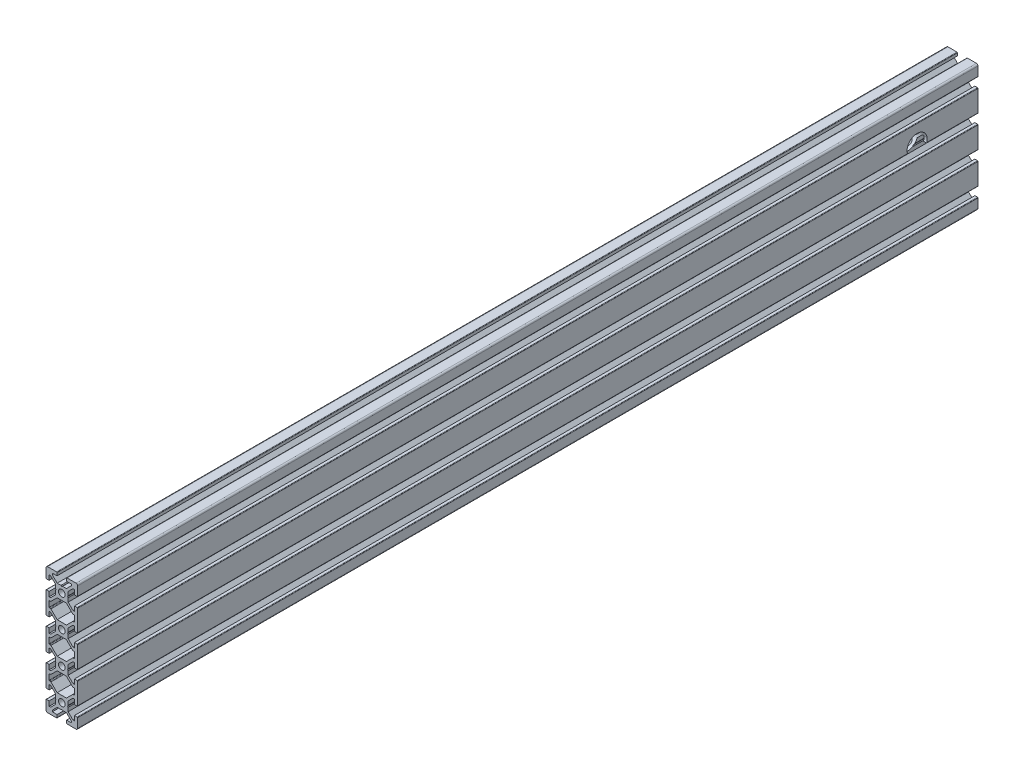
from build123d import *

# Parameters (mm, degrees)
SKETCH1_R           = 2.1
BOSS_EXTRUDE1_DEPTH = 569.5
SKETCH2_R           = 6.35
CUT_EXTRUDE1_DEPTH  = 20


with BuildPart() as part:
    # Sketch1 → Boss-Extrude1 (new body)
    with BuildSketch(Plane.XY):
        with BuildLine():
            Line((-9.7, -7), (-8, -7))
            Line((-8, -7), (-8, -4))
            Line((-8, -4), (-7.060612, -4))
            Line((-7.060612, -4), (-4, -7.06061195))
            Line((-4, -7.06061195), (-4, -9.480384758))
            Line((-4, -9.480384758), (-3.7, -10))
            Line((-3.7, -10), (-4, -10.519615242))
            Line((-4, -10.519615242), (-4, -12.939317))
            Line((-4, -12.939317), (-7.0606825, -16))
            Line((-7.0606825, -16), (-8, -16))
            Line((-8, -16), (-8, -13))
            Line((-8, -13), (-9.699997, -13))
            ThreePointArc((-9.699997, -13), (-9.912129034, -13.087871001), (-10, -13.30000305))
            Line((-10, -13.30000305), (-10, -26.699997))
            ThreePointArc((-10, -26.699997), (-9.912129041, -26.912129041), (-9.699997, -27))
            Line((-9.699997, -27), (-8, -27))
            Line((-8, -27), (-8, -24))
            Line((-8, -24), (-7.0606325, -24))
            Line((-7.0606325, -24), (-4, -27.0606334))
            Line((-4, -27.0606334), (-4, -29.480384758))
            Line((-4, -29.480384758), (-3.7, -30))
            Line((-3.7, -30), (-4, -30.519615242))
            Line((-4, -30.519615242), (-4, -32.9393376))
            Line((-4, -32.9393376), (-7.060661, -36))
            Line((-7.060661, -36), (-8, -36))
            Line((-8, -36), (-8, -33))
            Line((-8, -33), (-9.699997, -33))
            ThreePointArc((-9.699997, -33), (-9.912129041, -33.087870959), (-10, -33.300003))
            Line((-10, -33.300003), (-10, -39))
            ThreePointArc((-10, -39), (-9.707106781, -39.707106781), (-9, -40))
            Line((-9, -40), (-3.30000305, -40))
            ThreePointArc((-3.30000305, -40), (-3.087869903, -39.912135436), (-3, -39.7000045))
            Line((-3, -39.7000045), (-3, -38))
            Line((-3, -38), (-6, -38))
            Line((-6, -38), (-6, -37.060659))
            Line((-6, -37.060659), (-2.9393408, -34))
            Line((-2.9393408, -34), (-0.519615242, -34))
            Line((-0.519615242, -34), (0, -33.7))
            Line((0, -33.7), (0.519615242, -34))
            Line((0.519615242, -34), (2.9393408, -34))
            Line((2.9393408, -34), (6, -37.060659))
            Line((6, -37.060659), (6, -38))
            Line((6, -38), (3, -38))
            Line((3, -38), (3, -39.7000045))
            ThreePointArc((3, -39.7000045), (3.087869903, -39.912135436), (3.30000305, -40))
            Line((3.30000305, -40), (9, -40))
            ThreePointArc((9, -40), (9.707106781, -39.707106781), (10, -39))
            Line((10, -39), (10, -33.300003))
            ThreePointArc((10, -33.300003), (9.912129041, -33.087870959), (9.699997, -33))
            Line((9.699997, -33), (8, -33))
            Line((8, -33), (8, -36))
            Line((8, -36), (7.060661, -36))
            Line((7.060661, -36), (4, -32.9393376))
            Line((4, -32.9393376), (4, -30.519615242))
            Line((4, -30.519615242), (3.7, -30))
            Line((3.7, -30), (4, -29.480384758))
            Line((4, -29.480384758), (4, -27.0606334))
            Line((4, -27.0606334), (7.0606325, -24))
            Line((7.0606325, -24), (8, -24))
            Line((8, -24), (8, -27))
            Line((8, -27), (9.699997, -27))
            ThreePointArc((9.699997, -27), (9.912129041, -26.912129041), (10, -26.699997))
            Line((10, -26.699997), (10, -13.30000305))
            ThreePointArc((10, -13.30000305), (9.912129034, -13.087871001), (9.699997, -13))
            Line((9.699997, -13), (8, -13))
            Line((8, -13), (8, -16))
            Line((8, -16), (7.0606825, -16))
            Line((7.0606825, -16), (4, -12.939317))
            Line((4, -12.939317), (4, -10.519615242))
            Line((4, -10.519615242), (3.7, -10))
            Line((3.7, -10), (4, -9.480384758))
            Line((4, -9.480384758), (4, -7.06061195))
            Line((4, -7.06061195), (7.060612, -4))
            Line((7.060612, -4), (8, -4))
            Line((8, -4), (8, -7))
            Line((8, -7), (9.7, -7))
            ThreePointArc((9.7, -7), (9.912132034, -6.912132034), (10, -6.7))
            Line((10, -6.7), (10, 6.7))
            ThreePointArc((10, 6.7), (9.912132034, 6.912132034), (9.7, 7))
            Line((9.7, 7), (8, 7))
            Line((8, 7), (8, 4))
            Line((8, 4), (7.060612, 4))
            Line((7.060612, 4), (4, 7.06061195))
            Line((4, 7.06061195), (4, 9.480384758))
            Line((4, 9.480384758), (3.7, 10))
            Line((3.7, 10), (4, 10.519615242))
            Line((4, 10.519615242), (4, 12.939317))
            Line((4, 12.939317), (7.0606825, 16))
            Line((7.0606825, 16), (8, 16))
            Line((8, 16), (8, 13))
            Line((8, 13), (9.699997, 13))
            ThreePointArc((9.699997, 13), (9.912129034, 13.087871001), (10, 13.30000305))
            Line((10, 13.30000305), (10, 26.699997))
            ThreePointArc((10, 26.699997), (9.912129041, 26.912129041), (9.699997, 27))
            Line((9.699997, 27), (8, 27))
            Line((8, 27), (8, 24))
            Line((8, 24), (7.0606325, 24))
            Line((7.0606325, 24), (4, 27.0606334))
            Line((4, 27.0606334), (4, 29.480384758))
            Line((4, 29.480384758), (3.7, 30))
            Line((3.7, 30), (4, 30.519615242))
            Line((4, 30.519615242), (4, 32.9393376))
            Line((4, 32.9393376), (7.060661, 36))
            Line((7.060661, 36), (8, 36))
            Line((8, 36), (8, 33))
            Line((8, 33), (9.699997, 33))
            ThreePointArc((9.699997, 33), (9.912129041, 33.087870959), (10, 33.300003))
            Line((10, 33.300003), (10, 39))
            ThreePointArc((10, 39), (9.707106781, 39.707106781), (9, 40))
            Line((9, 40), (3.30000305, 40))
            ThreePointArc((3.30000305, 40), (3.087869903, 39.912135436), (3, 39.7000045))
            Line((3, 39.7000045), (3, 38))
            Line((3, 38), (6, 38))
            Line((6, 38), (6, 37.060659))
            Line((6, 37.060659), (2.9393408, 34))
            Line((2.9393408, 34), (0.519615242, 34))
            Line((0.519615242, 34), (0, 33.7))
            Line((0, 33.7), (-0.519615242, 34))
            Line((-0.519615242, 34), (-2.9393408, 34))
            Line((-2.9393408, 34), (-6, 37.060659))
            Line((-6, 37.060659), (-6, 38))
            Line((-6, 38), (-3, 38))
            Line((-3, 38), (-3, 39.7000045))
            ThreePointArc((-3, 39.7000045), (-3.087869903, 39.912135436), (-3.30000305, 40))
            Line((-3.30000305, 40), (-9, 40))
            ThreePointArc((-9, 40), (-9.707106781, 39.707106781), (-10, 39))
            Line((-10, 39), (-10, 33.300003))
            ThreePointArc((-10, 33.300003), (-9.912129041, 33.087870959), (-9.699997, 33))
            Line((-9.699997, 33), (-8, 33))
            Line((-8, 33), (-8, 36))
            Line((-8, 36), (-7.060661, 36))
            Line((-7.060661, 36), (-4, 32.9393376))
            Line((-4, 32.9393376), (-4, 30.519615242))
            Line((-4, 30.519615242), (-3.7, 30))
            Line((-3.7, 30), (-4, 29.480384758))
            Line((-4, 29.480384758), (-4, 27.0606334))
            Line((-4, 27.0606334), (-7.0606325, 24))
            Line((-7.0606325, 24), (-8, 24))
            Line((-8, 24), (-8, 27))
            Line((-8, 27), (-9.699997, 27))
            ThreePointArc((-9.699997, 27), (-9.912129041, 26.912129041), (-10, 26.699997))
            Line((-10, 26.699997), (-10, 13.30000305))
            ThreePointArc((-10, 13.30000305), (-9.912129034, 13.087871001), (-9.699997, 13))
            Line((-9.699997, 13), (-8, 13))
            Line((-8, 13), (-8, 16))
            Line((-8, 16), (-7.0606825, 16))
            Line((-7.0606825, 16), (-4, 12.939317))
            Line((-4, 12.939317), (-4, 10.519615242))
            Line((-4, 10.519615242), (-3.7, 10))
            Line((-3.7, 10), (-4, 9.480384758))
            Line((-4, 9.480384758), (-4, 7.06061195))
            Line((-4, 7.06061195), (-7.060612, 4))
            Line((-7.060612, 4), (-8, 4))
            Line((-8, 4), (-8, 7))
            Line((-8, 7), (-9.7, 7))
            ThreePointArc((-9.7, 7), (-9.912132034, 6.912132034), (-10, 6.7))
            Line((-10, 6.7), (-10, -6.7))
            ThreePointArc((-10, -6.7), (-9.912132034, -6.912132034), (-9.7, -7))
        make_face()
        with Locations((0, 30)):
            Circle(SKETCH1_R, mode=Mode.SUBTRACT)
        with Locations((0, 10)):
            Circle(SKETCH1_R, mode=Mode.SUBTRACT)
        with Locations((0, -10)):
            Circle(SKETCH1_R, mode=Mode.SUBTRACT)
        with Locations((0, -30)):
            Circle(SKETCH1_R, mode=Mode.SUBTRACT)
        with BuildLine():
            Line((-7.7, -2), (-7.0635985, -2))
            ThreePointArc((-7.0635985, -2), (-6.948788713, -2.022765099), (-6.851481488, -2.087810012))
            Line((-6.851481488, -2.087810012), (-2.93929195, -6))
            Line((-2.93929195, -6), (2.93929195, -6))
            Line((2.93929195, -6), (6.851481488, -2.087810012))
            ThreePointArc((6.851481488, -2.087810012), (6.948788713, -2.022765099), (7.0635985, -2))
            Line((7.0635985, -2), (7.7, -2))
            ThreePointArc((7.7, -2), (7.912132034, -1.912132034), (8, -1.7))
            Line((8, -1.7), (8, 1.7))
            ThreePointArc((8, 1.7), (7.912132034, 1.912132034), (7.7, 2))
            Line((7.7, 2), (7.0635985, 2))
            ThreePointArc((7.0635985, 2), (6.948788713, 2.022765099), (6.851481488, 2.087810012))
            Line((6.851481488, 2.087810012), (2.93929195, 6))
            Line((2.93929195, 6), (-2.93929195, 6))
            Line((-2.93929195, 6), (-6.851481488, 2.087810012))
            ThreePointArc((-6.851481488, 2.087810012), (-6.948788713, 2.022765099), (-7.0635985, 2))
            Line((-7.0635985, 2), (-7.7, 2))
            ThreePointArc((-7.7, 2), (-7.912132034, 1.912132034), (-8, 1.7))
            Line((-8, 1.7), (-8, -1.7))
            ThreePointArc((-8, -1.7), (-7.912132034, -1.912132034), (-7.7, -2))
        make_face(mode=Mode.SUBTRACT)
        with BuildLine():
            Line((-8, 21.699951), (-8, 18.299927))
            ThreePointArc((-8, 18.299927), (-7.91214017, 18.087806084), (-7.699997, 18))
            Line((-7.699997, 18), (-7.0635985, 18))
            ThreePointArc((-7.0635985, 18), (-6.948796612, 17.977116172), (-6.851455999, 17.912093499))
            Line((-6.851455999, 17.912093499), (-2.93936255, 14))
            Line((-2.93936255, 14), (2.93936255, 14))
            Line((2.93936255, 14), (6.851455999, 17.912093499))
            ThreePointArc((6.851455999, 17.912093499), (6.948796612, 17.977116172), (7.0635985, 18))
            Line((7.0635985, 18), (7.699997, 18))
            ThreePointArc((7.699997, 18), (7.91214017, 18.087806084), (8, 18.299927))
            Line((8, 18.299927), (8, 21.699951))
            ThreePointArc((8, 21.699951), (7.912122304, 21.91208978), (7.699997, 22))
            Line((7.699997, 22), (7.0635985, 22))
            ThreePointArc((7.0635985, 22), (6.94879007, 22.022764537), (6.851491978, 22.087820522))
            Line((6.851491978, 22.087820522), (2.9393133, 26))
            Line((2.9393133, 26), (-2.9393133, 26))
            Line((-2.9393133, 26), (-6.851491978, 22.087820522))
            ThreePointArc((-6.851491978, 22.087820522), (-6.94879007, 22.022764537), (-7.0635985, 22))
            Line((-7.0635985, 22), (-7.699997, 22))
            ThreePointArc((-7.699997, 22), (-7.912122304, 21.91208978), (-8, 21.699951))
        make_face(mode=Mode.SUBTRACT)
        with BuildLine():
            Line((-8, -18.299927), (-8, -21.699951))
            ThreePointArc((-8, -21.699951), (-7.912122304, -21.91208978), (-7.699997, -22))
            Line((-7.699997, -22), (-7.0635985, -22))
            ThreePointArc((-7.0635985, -22), (-6.94879007, -22.022764537), (-6.851491978, -22.087820522))
            Line((-6.851491978, -22.087820522), (-2.9393133, -26))
            Line((-2.9393133, -26), (2.9393133, -26))
            Line((2.9393133, -26), (6.851491978, -22.087820522))
            ThreePointArc((6.851491978, -22.087820522), (6.94879007, -22.022764537), (7.0635985, -22))
            Line((7.0635985, -22), (7.699997, -22))
            ThreePointArc((7.699997, -22), (7.912122304, -21.91208978), (8, -21.699951))
            Line((8, -21.699951), (8, -18.299927))
            ThreePointArc((8, -18.299927), (7.91214017, -18.087806084), (7.699997, -18))
            Line((7.699997, -18), (7.0635985, -18))
            ThreePointArc((7.0635985, -18), (6.948796612, -17.977116172), (6.851455999, -17.912093499))
            Line((6.851455999, -17.912093499), (2.93936255, -14))
            Line((2.93936255, -14), (-2.93936255, -14))
            Line((-2.93936255, -14), (-6.851455999, -17.912093499))
            ThreePointArc((-6.851455999, -17.912093499), (-6.948796612, -17.977116172), (-7.0635985, -18))
            Line((-7.0635985, -18), (-7.699997, -18))
            ThreePointArc((-7.699997, -18), (-7.91214017, -18.087806084), (-8, -18.299927))
        make_face(mode=Mode.SUBTRACT)
    extrude(amount=-BOSS_EXTRUDE1_DEPTH)

    # Sketch2 → Cut-Extrude1 (cut)
    with BuildSketch(Plane(origin=(10, 0, 0), x_dir=(0, 0, -1), z_dir=(1, 0, 0))):
        with Locations((531, 15)):
            Circle(SKETCH2_R)
    extrude(amount=-CUT_EXTRUDE1_DEPTH, mode=Mode.SUBTRACT)


solid = part.part
